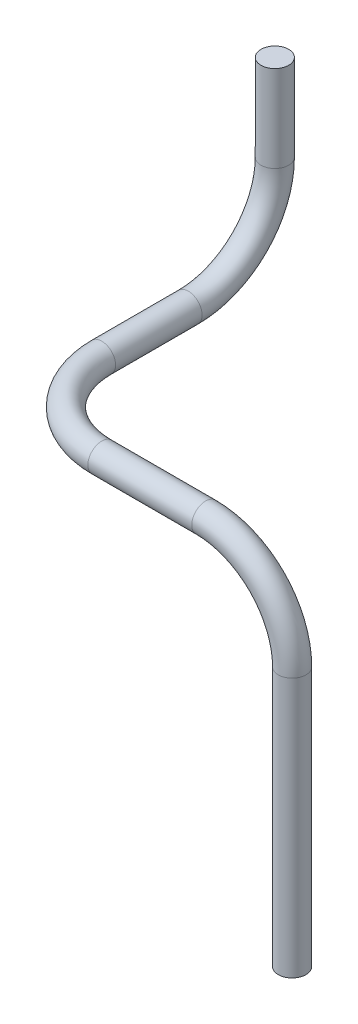
from build123d import *

# Parameters (mm, degrees)
SKETCH1_R = 0.8


with BuildPart() as part:
    # Sweep1: sweep along a curve in space
    with BuildLine() as sweep1_path:
        Line((0, 0, 0), (0, -5, 0))
        ThreePointArc((0, -5, 0), (0, -8.535533906, 1.464466094), (0, -10, 5))
        Line((0, -10, 5), (0, -10, 10))
        ThreePointArc((0, -10, 10), (1.464466094, -10, 13.535533906), (5, -10, 15))
        Line((5, -10, 15), (11, -10, 15))
        ThreePointArc((11, -10, 15), (14.535533906, -11.464466094, 15), (16, -15, 15))
        Line((16, -15, 15), (16, -30, 15))
    # Sketch1 → Sweep1 (sweep)
    with BuildSketch(Plane(origin=(0, 0, 0), x_dir=(1, 0, 0), z_dir=(0, 1, 0))):
        Circle(SKETCH1_R)
    sweep(path=sweep1_path.line)


solid = part.part
